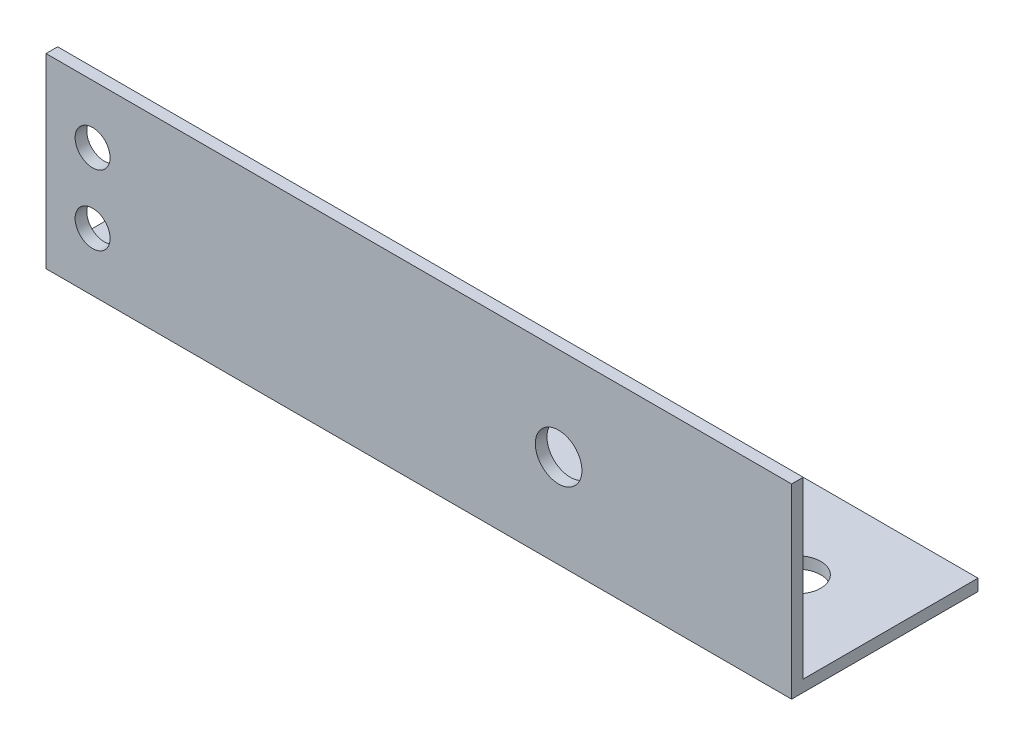
from build123d import *

# Parameters (mm, degrees)
BOSS_EXTRUDE1_DEPTH = 101.6
SKETCH2_R           = 3.175
CUT_EXTRUDE1_DEPTH  = 101.6
SKETCH3_R           = 3.175
SKETCH3_R_2         = 2.38125
CUT_EXTRUDE2_DEPTH  = 101.6
SKETCH4_W           = 29.676804306
SKETCH4_H           = 30.942193328
CUT_EXTRUDE3_DEPTH  = 101.6


with BuildPart() as part:
    # Sketch1 → Boss-Extrude1 (new body)
    with BuildSketch(Plane(origin=(0, 0, 0), x_dir=(0, 0, -1), z_dir=(1, 0, 0))):
        Polygon((0, 0), (0, 25.4), (-1.5875, 25.4), (-1.5875, 1.5875), (-25.4, 1.5875), (-25.4, 0), align=None)
    boss_extrude1 = extrude(amount=BOSS_EXTRUDE1_DEPTH)

    # Sketch2 → Cut-Extrude1 (cut)
    with BuildSketch(Plane(origin=(0, 1.5875, 0), x_dir=(1, 0, 0), z_dir=(0, 1, 0))):
        with Locations((12.7, -13.49375)):
            Circle(SKETCH2_R)
        with Locations((88.9, -13.49375)):
            Circle(SKETCH2_R)
    cut_extrude1 = extrude(amount=-CUT_EXTRUDE1_DEPTH, mode=Mode.SUBTRACT)

    # Sketch3 → Cut-Extrude2 (cut)
    with BuildSketch(Plane.XY.offset(1.5875)):
        with Locations((69.85, 12.7)):
            Circle(SKETCH3_R)
        with Locations((6.35, 17.4625)):
            Circle(SKETCH3_R_2)
        with Locations((6.35, 7.9375)):
            Circle(SKETCH3_R_2)
    cut_extrude2 = extrude(amount=-CUT_EXTRUDE2_DEPTH, mode=Mode.SUBTRACT)

    # Mirror1: Boss-Extrude1, Cut-Extrude1, Cut-Extrude2 across plane
    add(boss_extrude1.mirror(Plane(origin=(101.6, 0, 0), x_dir=(1, 0, 0), z_dir=(0, 0, 1))))
    add(cut_extrude1.mirror(Plane(origin=(101.6, 0, 0), x_dir=(1, 0, 0), z_dir=(0, 0, 1))), mode=Mode.SUBTRACT)
    add(cut_extrude2.mirror(Plane(origin=(101.6, 0, 0), x_dir=(1, 0, 0), z_dir=(0, 0, 1))), mode=Mode.SUBTRACT)

    # Sketch4 → Cut-Extrude3 (cut)
    with BuildSketch(Plane.ZY):
        with Locations((14.838402153, 15.471096664)):
            Rectangle(SKETCH4_W, SKETCH4_H)
    extrude(amount=-CUT_EXTRUDE3_DEPTH, mode=Mode.SUBTRACT)


solid = part.part
